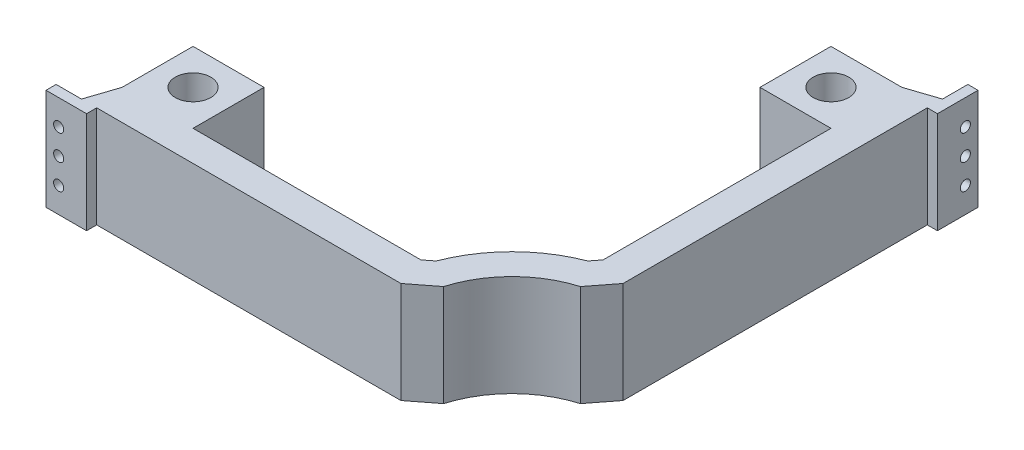
from build123d import *

# Parameters (mm, degrees)
BOSS_EXTRUDE1_DEPTH = 50
SKETCH3_R           = 8.75
CUT_EXTRUDE1_DEPTH  = 50
SKETCH5_R           = 2.5
CUT_EXTRUDE3_DEPTH  = 10
SKETCH6_R           = 2.5
CUT_EXTRUDE4_DEPTH  = 10


with BuildPart() as part:
    # Sketch2 → Boss-Extrude1 (new body)
    with BuildSketch(Plane(origin=(0, 0, 0), x_dir=(1, 0, 0), z_dir=(0, 1, 0))):
        with BuildLine():
            Line((-54.874212294, -102.775031025), (47.605671551, -102.775031025))
            Line((47.605671551, -102.775031025), (59.453092269, -93.575105898))
            ThreePointArc((59.453092269, -93.575105898), (72.038989389, -72.419691965), (93.194403322, -59.833794845))
            Line((93.194403322, -59.833794845), (102.394328449, -47.986374127))
            Line((102.394328449, -47.986374127), (102.394328449, 56.694970167))
            Line((102.394328449, 56.694970167), (102.394328449, 102.013625873))
            Line((102.394328449, 102.013625873), (107.394328449, 102.013625873))
            Line((107.394328449, 102.013625873), (107.394328449, 122.013625873))
            Line((107.394328449, 122.013625873), (102.394328449, 122.013625873))
            Line((102.394328449, 122.013625873), (102.394328449, 109.513625873))
            Line((102.394328449, 109.513625873), (87.394328449, 104.513625873))
            Line((87.394328449, 104.513625873), (52.394328449, 104.513625873))
            Line((52.394328449, 104.513625873), (52.394328449, 69.513625873))
            Line((52.394328449, 69.513625873), (87.394328449, 69.513625873))
            Line((87.394328449, 69.513625873), (87.394328449, -42.846257379))
            Line((87.394328449, -42.846257379), (84.095735231, -47.094098648))
            ThreePointArc((84.095735231, -47.094098648), (61.432387672, -61.813090248), (46.713396072, -84.476437807))
            Line((46.713396072, -84.476437807), (42.465554802, -87.775031025))
            Line((42.465554802, -87.775031025), (-69.894328449, -87.775031025))
            Line((-69.894328449, -87.775031025), (-69.894328449, -52.775031025))
            Line((-69.894328449, -52.775031025), (-104.894328449, -52.775031025))
            Line((-104.894328449, -52.775031025), (-104.894328449, -87.775031025))
            Line((-104.894328449, -87.775031025), (-109.894328449, -102.775031025))
            Line((-109.894328449, -102.775031025), (-122.394328449, -102.775031025))
            Line((-122.394328449, -102.775031025), (-122.394328449, -107.775031025))
            Line((-122.394328449, -107.775031025), (-102.394328449, -107.775031025))
            Line((-102.394328449, -107.775031025), (-102.394328449, -102.775031025))
            Line((-102.394328449, -102.775031025), (-54.874212294, -102.775031025))
        make_face()
    extrude(amount=BOSS_EXTRUDE1_DEPTH)

    # Sketch3 → Cut-Extrude1 (cut)
    with BuildSketch(Plane(origin=(0, 50, 0), x_dir=(1, 0, 0), z_dir=(0, 1, 0))):
        with Locations((-87.394328449, -70.275031025)):
            Circle(SKETCH3_R)
        with Locations((69.894328449, 87.013625873)):
            Circle(SKETCH3_R)
    extrude(amount=-CUT_EXTRUDE1_DEPTH, mode=Mode.SUBTRACT)

    # Sketch5 → Cut-Extrude3 (cut)
    with BuildSketch(Plane(origin=(0, 0, 102.775031025), x_dir=(-1, 0, 0), z_dir=(0, 0, -1))):
        with Locations((116.144328449, 37.5)):
            Circle(SKETCH5_R)
        with Locations((116.144328449, 25)):
            Circle(SKETCH5_R)
        with Locations((116.144328449, 12.5)):
            Circle(SKETCH5_R)
    extrude(amount=-CUT_EXTRUDE3_DEPTH, mode=Mode.SUBTRACT)

    # Sketch6 → Cut-Extrude4 (cut)
    with BuildSketch(Plane.ZY.offset(-102.394328449)):
        with Locations((-115.763625873, 37.5)):
            Circle(SKETCH6_R)
        with Locations((-115.763625873, 25)):
            Circle(SKETCH6_R)
        with Locations((-115.763625873, 12.5)):
            Circle(SKETCH6_R)
    extrude(amount=-CUT_EXTRUDE4_DEPTH, mode=Mode.SUBTRACT)


solid = part.part
